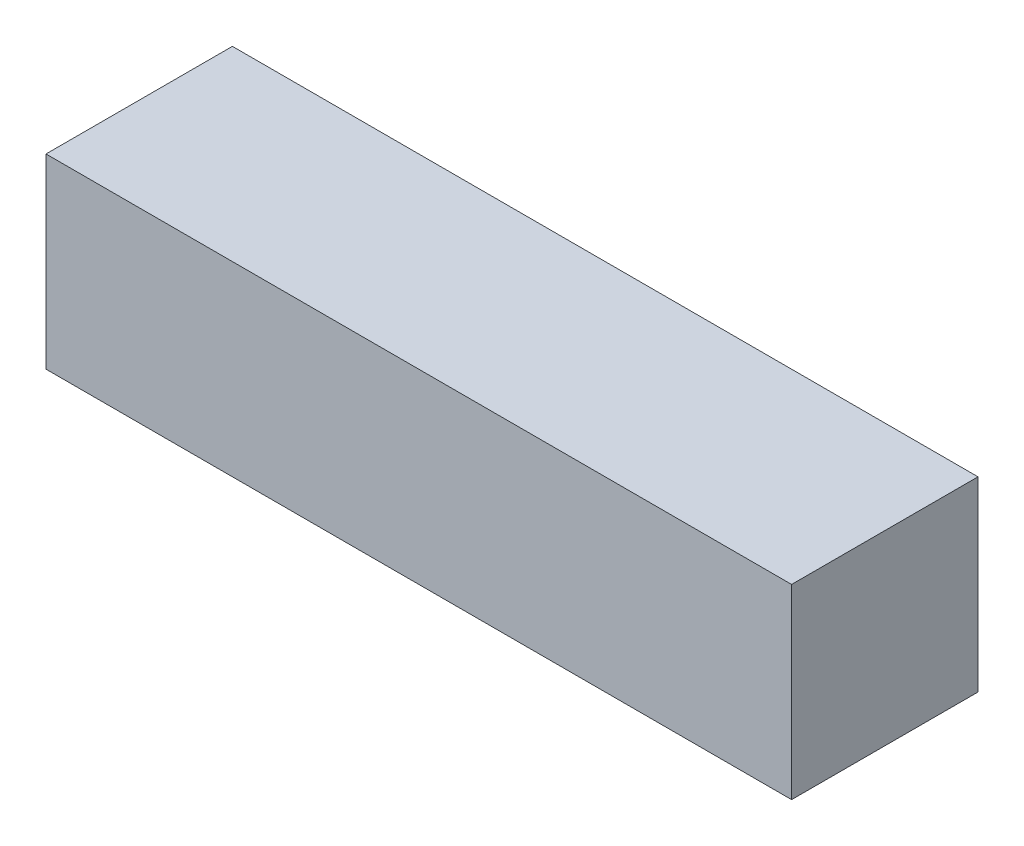
from build123d import *

# Parameters (mm, degrees)
SKETCH1_W      = 12.7
SKETCH1_H      = 3.175
EXTRUDE1_DEPTH = 3.175


with BuildPart() as part:
    # Sketch1 → Extrude1 (new body)
    with BuildSketch(Plane(origin=(0, 0, 0), x_dir=(1, 0, 0), z_dir=(0, 1, 0))):
        Rectangle(SKETCH1_W, SKETCH1_H)
    extrude(amount=-EXTRUDE1_DEPTH)


solid = part.part
